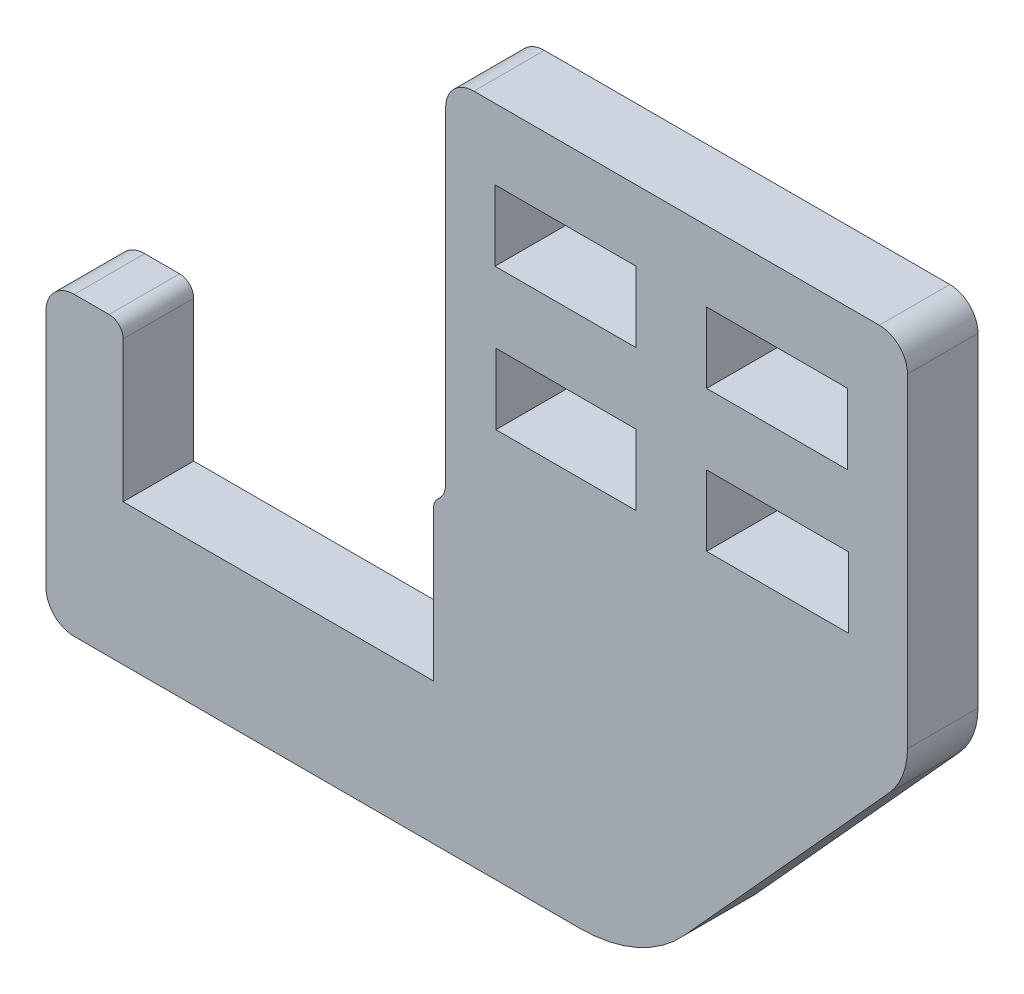
from build123d import *

# Parameters (mm, degrees)
SKETCH1_W           = 10
SKETCH1_H           = 5
SKETCH1_W_2         = 9.935990319
SKETCH1_W_3         = 10.064009681
BOSS_EXTRUDE1_DEPTH = 5


with BuildPart() as part:
    # Sketch1 → Boss-Extrude1 (new body)
    with BuildSketch(Plane.XY):
        with BuildLine():
            Line((44.999999787, 7.5), (44.999999787, 30.5))
            ThreePointArc((44.999999787, 30.5), (44.41421335, 31.914213562), (42.999999787, 32.5))
            Line((42.999999787, 32.5), (14.260362516, 32.5))
            ThreePointArc((14.260362516, 32.5), (12.846148953, 31.914213562), (12.260362516, 30.5))
            Line((12.260362516, 30.5), (12.260362516, 7.356217509))
            ThreePointArc((12.260362516, 7.356217509), (12.125280096, 6.734124269), (11.744362516, 6.224076175))
            ThreePointArc((11.744362516, 6.224076175), (11.490417462, 5.884044113), (11.400362516, 5.469315286))
            Line((11.400362516, 5.469315286), (11.400362516, -5.143782491))
            Line((11.400362516, -5.143782491), (-10.599637484, -5.143782491))
            Line((-10.599637484, -5.143782491), (-10.599637484, 4.856217509))
            ThreePointArc((-10.599637484, 4.856217509), (-10.892530703, 5.563324291), (-11.599637484, 5.856217509))
            Line((-11.599637484, 5.856217509), (-14.070705683, 5.856217509))
            ThreePointArc((-14.070705683, 5.856217509), (-15.484919246, 5.270431072), (-16.070705683, 3.856217509))
            Line((-16.070705683, 3.856217509), (-16.070705683, -13.143782491))
            ThreePointArc((-16.070705683, -13.143782491), (-15.484919246, -14.557996053), (-14.070705683, -15.143782491))
            Line((-14.070705683, -15.143782491), (21.781895091, -15.143782491))
            ThreePointArc((21.781895091, -15.143782491), (25.832683233, -14.286600187), (29.189018592, -11.862005577))
            Line((29.189018592, -11.862005577), (43.703561538, 4.140888457))
            ThreePointArc((43.703561538, 4.140888457), (44.664643865, 5.699695686), (44.999999787, 7.5))
        make_face()
        with Locations((20.760362516, 25)):
            Rectangle(SKETCH1_W, SKETCH1_H, mode=Mode.SUBTRACT)
        with Locations((20.792367357, 14.995460919)):
            Rectangle(SKETCH1_W_2, SKETCH1_H, mode=Mode.SUBTRACT)
        with Locations((35.760362516, 25)):
            Rectangle(SKETCH1_W, SKETCH1_H, mode=Mode.SUBTRACT)
        with Locations((35.792367357, 14.995460919)):
            Rectangle(SKETCH1_W_3, SKETCH1_H, mode=Mode.SUBTRACT)
    extrude(amount=BOSS_EXTRUDE1_DEPTH)


solid = part.part
